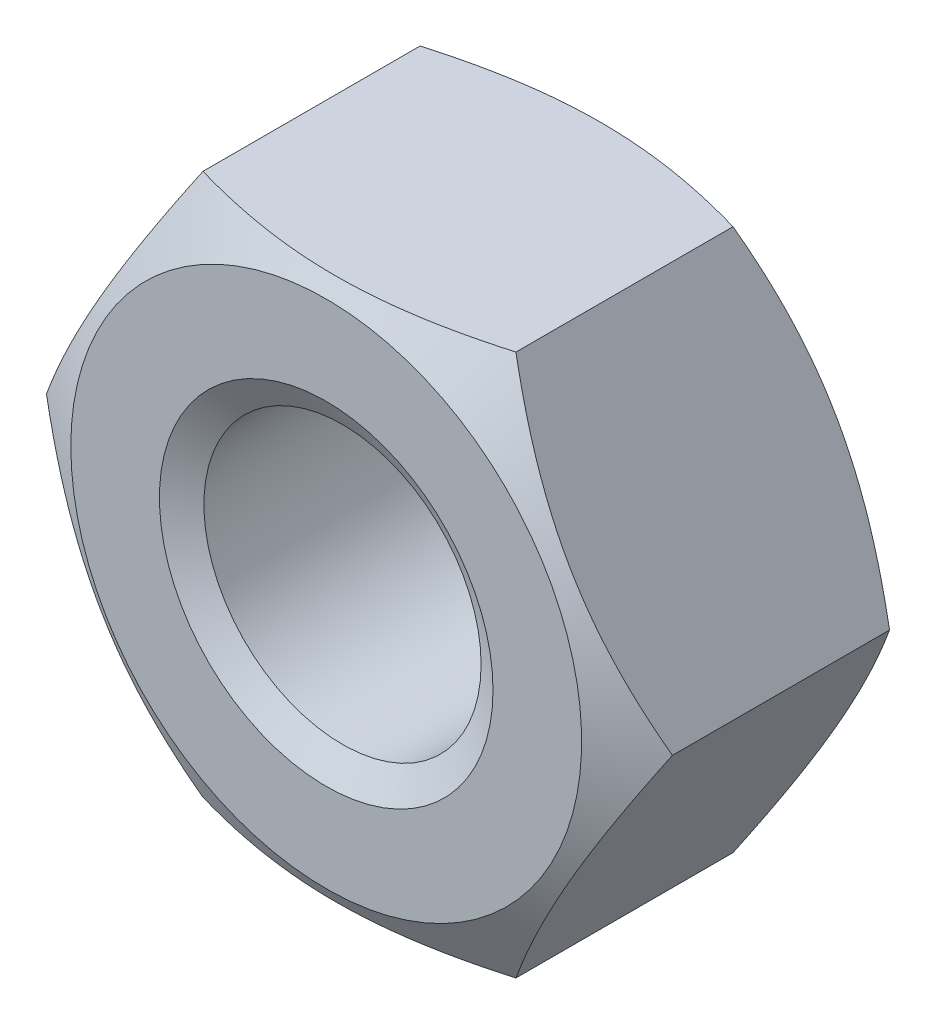
from build123d import *

# Parameters (mm, degrees)
SKETCH1_R               = 3.3235
BASENUT_DEPTH           = 6.8
ENDCHAMFER_SIZE         = 0.6765
ENDCHAMFER_SIZE2        = 0.390577457
ENDCHAMFER_PART_2_SIZE  = 0.6765
ENDCHAMFER_PART_2_SIZE2 = 0.390577457


with BuildPart() as part:
    # Sketch1 → BaseNut (new body)
    with BuildSketch(Plane.XY):
        Polygon((7.505553499, 0), (3.75277675, 6.5), (-3.75277675, 6.5), (-7.505553499, 0), (-3.75277675, -6.5), (3.75277675, -6.5), align=None)
        Circle(SKETCH1_R, mode=Mode.SUBTRACT)
    extrude(amount=-BASENUT_DEPTH)

    # Sketch2 → Double-Chamfer (revolve, cut)
    with BuildSketch(Plane(origin=(0, 0, 0), x_dir=(1, 0, 0), z_dir=(0, 1, 0))):
        Polygon((-7.505553499, 6.8), (-6.125, 6.8), (-7.505553499, 6.002937065), align=None)
        Polygon((-7.505553499, 0.797062935), (-7.505553499, 0), (-6.125, 0), align=None)
    revolve(axis=Axis((0, 0, -3.375940562), (0, 0, 1)), mode=Mode.SUBTRACT)

    # EndChamfer
    endchamfer_edges = [part.edges().sort_by_distance(p)[0] for p in [
        (-3.3235, 0, -6.8),
    ]]
    endchamfer_side = [part.faces().sort_by_distance(p)[0] for p in [
        (-3.3235, 0, -3.4),
    ]]
    chamfer(endchamfer_edges, length=ENDCHAMFER_SIZE, length2=ENDCHAMFER_SIZE2, reference=endchamfer_side[0])

    # EndChamfer part 2
    endchamfer_part_2_edges = [part.edges().sort_by_distance(p)[0] for p in [
        (-3.3235, 0, 0),
    ]]
    endchamfer_part_2_side = [part.faces().sort_by_distance(p)[0] for p in [
        (5.951758839, 0, 0),
    ]]
    chamfer(endchamfer_part_2_edges, length=ENDCHAMFER_PART_2_SIZE, length2=ENDCHAMFER_PART_2_SIZE2, reference=endchamfer_part_2_side[0])


solid = part.part
